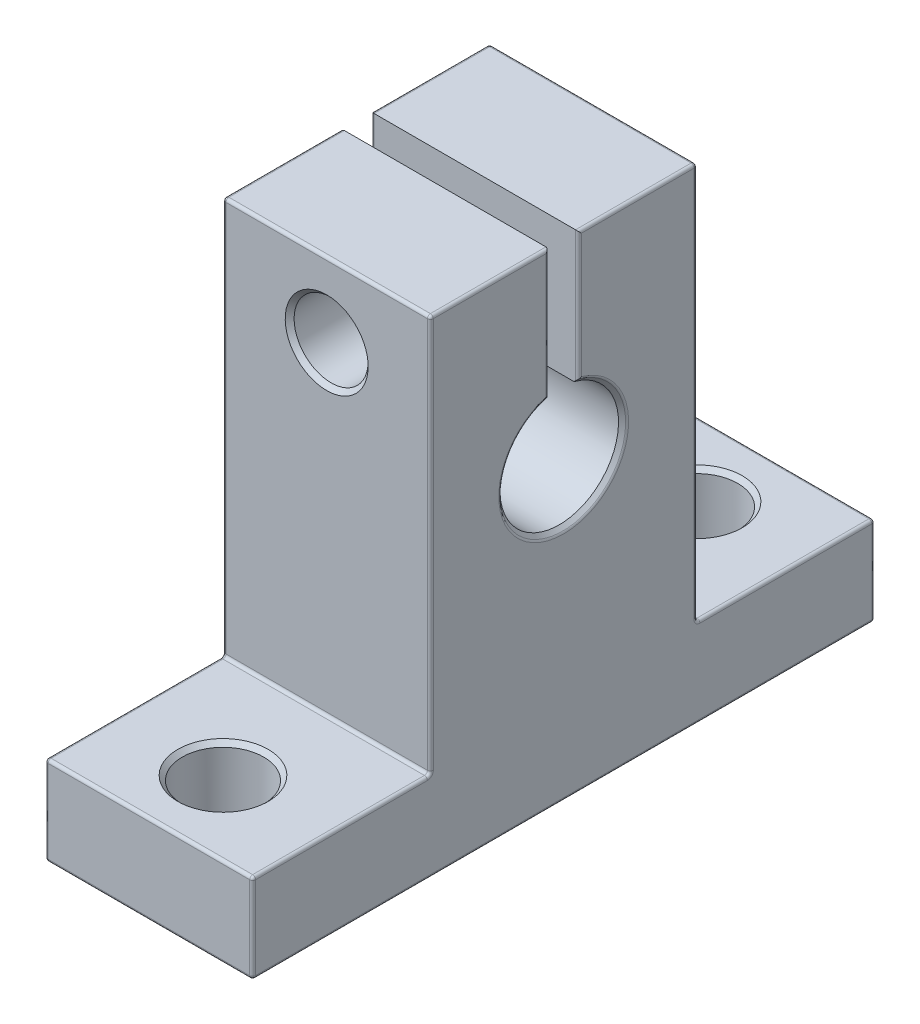
from build123d import *

# Parameters (mm, degrees)
BOSS_EXTRUDE1_DEPTH = 7
SKETCH4_R           = 2.75
CUT_EXTRUDE3_DEPTH  = 7
SKETCH6_R           = 2.5
CUT_EXTRUDE4_DEPTH  = 31
SKETCH7_R           = 4
CUT_EXTRUDE5_DEPTH  = 5
CHAMFER_1_SIZE      = 0.3
FILLET_1_R          = 0.2


with BuildPart() as part:
    # Sketch1 → Boss-Extrude1 (new body, symmetric)
    with BuildSketch(Plane(origin=(0, 0, 0), x_dir=(0, 0, -1), z_dir=(1, 0, 0))):
        with BuildLine():
            Line((-21, 0), (21, 0))
            Line((21, 0), (21, 6))
            Line((21, 6), (9, 6))
            Line((9, 6), (9, 32.8))
            Line((9, 32.8), (1, 32.8))
            Line((1, 32.8), (1, 23.872983346))
            ThreePointArc((1, 23.872983346), (0, 16), (-1, 23.872983346))
            Line((-1, 23.872983346), (-1, 32.8))
            Line((-1, 32.8), (-9, 32.8))
            Line((-9, 32.8), (-9, 6))
            Line((-9, 6), (-21, 6))
            Line((-21, 6), (-21, 0))
        make_face()
    extrude(amount=BOSS_EXTRUDE1_DEPTH, both=True)

    # Sketch4 → Cut-Extrude3 (cut, through all)
    with BuildSketch(Plane(origin=(0, 6, 0), x_dir=(1, 0, 0), z_dir=(0, 1, 0))):
        with Locations(Location((0, -16, 0), (0, 0, 270))):  # turned: the seam where the file's is
            Circle(SKETCH4_R)
        with Locations(Location((0, 16, 0), (0, 0, 270))):  # turned: the seam where the file's is
            Circle(SKETCH4_R)
    extrude(amount=-CUT_EXTRUDE3_DEPTH, mode=Mode.SUBTRACT)

    # Sketch6 → Cut-Extrude4 (cut, through all)
    with BuildSketch(Plane(origin=(0, 0, -9), x_dir=(-1, 0, 0), z_dir=(0, 0, -1))):
        with Locations(Location((0, 27.8, 0), (0, 0, 90))):  # turned: the seam where the file's is
            Circle(SKETCH6_R)
    extrude(amount=-CUT_EXTRUDE4_DEPTH, mode=Mode.SUBTRACT)

    # Sketch7 → Cut-Extrude5 (cut)
    with BuildSketch(Plane(origin=(0, 0, -9), x_dir=(-1, 0, 0), z_dir=(0, 0, -1))):
        with Locations(Location((0, 27.8, 0), (0, 0, 90))):  # turned: the seam where the file's is
            Circle(SKETCH7_R)
    extrude(amount=-CUT_EXTRUDE5_DEPTH, mode=Mode.SUBTRACT)

    # Фаска1
    chamfer_1_edges = [part.edges().sort_by_distance(p)[0] for p in [
        (-7, 16, 0),
        (7, 16, 0),
        (0, 0, 13.25),
        (0, 6, 13.25),
        (0, 0, -18.75),
        (0, 6, -18.75),
        (0, 25.3, 9),
        (0, 23.8, -9),
    ]]
    chamfer(chamfer_1_edges, length=CHAMFER_1_SIZE)

    # Скругление1
    fillet_1_edges = [part.edges().sort_by_distance(p)[0] for p in [
        (-7, 32.8, 5),
        (-7, 19.4, 9),
        (-7, 6, 15),
        (-7, 3, 21),
        (-7, 0, 0),
        (-7, 3, -21),
        (-7, 6, -15),
        (-7, 19.4, -9),
        (-7, 32.8, -5),
        (-7, 28.491052367, -1),
        (-7, 15.7, 0),
        (-7, 28.491052367, 1),
        (7, 32.8, -5),
        (7, 19.4, -9),
        (7, 6, -15),
        (7, 3, -21),
        (7, 0, 0),
        (7, 3, 21),
        (7, 6, 15),
        (7, 19.4, 9),
        (7, 32.8, 5),
        (7, 28.491052367, 1),
        (7, 15.7, 0),
        (7, 28.491052367, -1),
        (0, 0, 21),
        (0, 6, 9),
        (0, 6, 21),
        (0, 32.8, 9),
        (0, 0, -21),
        (0, 32.8, -9),
        (0, 6, -9),
        (0, 6, -21),
    ]]
    fillet(fillet_1_edges, radius=FILLET_1_R)


solid = part.part
